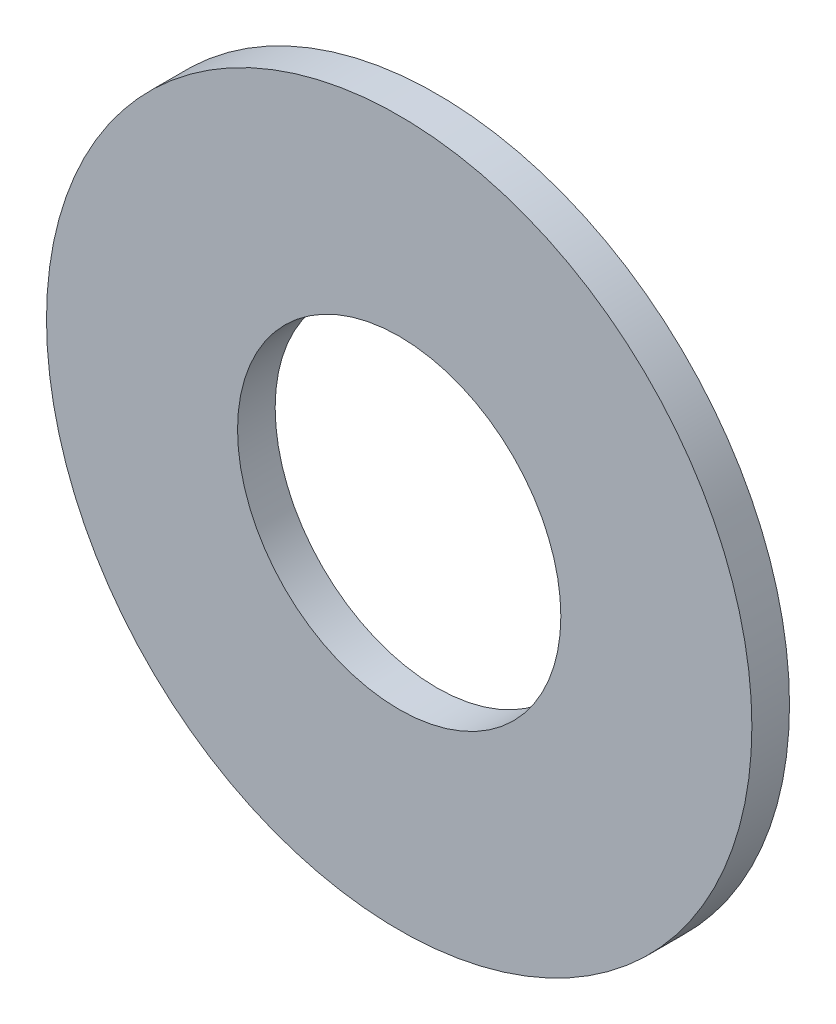
from build123d import *

# Parameters (mm, degrees)
SKETCH1_R      = 9.525
SKETCH1_R_2    = 4.365625
EXTRUDE1_DEPTH = 1.016


with BuildPart() as part:
    # Sketch1 → Extrude1 (new body)
    with BuildSketch(Plane.XY):
        Circle(SKETCH1_R)
        Circle(SKETCH1_R_2, mode=Mode.SUBTRACT)
    extrude(amount=-EXTRUDE1_DEPTH)


solid = part.part
